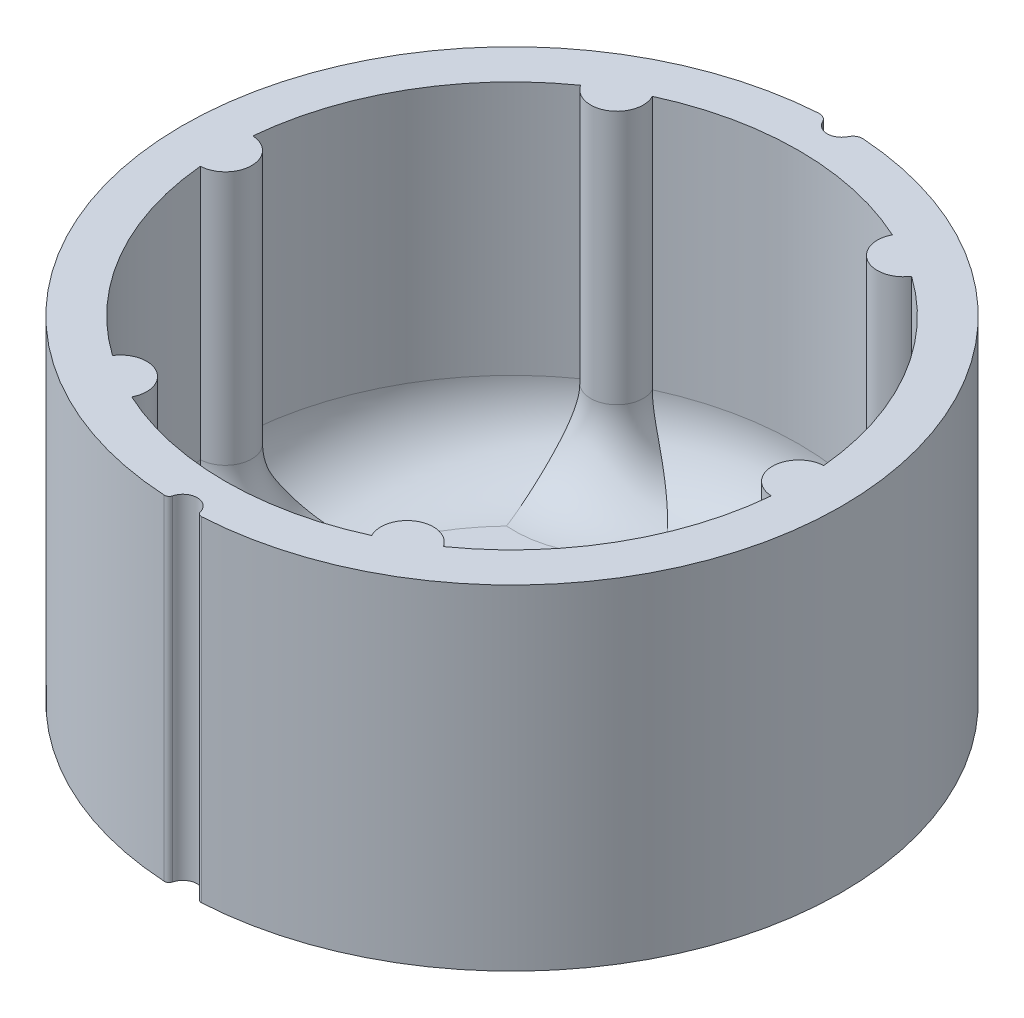
from build123d import *

# Parameters (mm, degrees)
BOSS_EXTRUDE1_DEPTH = 35
CUT_EXTRUDE2_DEPTH  = 61.012997416
BOSS_EXTRUDE2_DEPTH = 0.4
FILLET1_R           = 8


with BuildPart() as part:
    # Sketch1 → Boss-Extrude1 (new body)
    with BuildSketch(Plane(origin=(0, 0, 0), x_dir=(1, 0, 0), z_dir=(0, 1, 0))):
        with BuildLine():
            ThreePointArc((1.451818925, -34.068556857), (1.641248992, -34.346908706), (1.964225605, -34.442038138))
            ThreePointArc((1.964225605, -34.442038138), (26.591847487, -21.978073076), (34.198225299, 4.555174015))
            ThreePointArc((34.198225299, 4.555174015), (23.590291339, 25.176355888), (2.324135821, 34.423627607))
            ThreePointArc((2.324135821, 34.423627607), (1.751838249, 34.289058819), (1.354061739, 33.856153382))
            ThreePointArc((1.354061739, 33.856153382), (0, 33.001534515), (-1.354061739, 33.856153382))
            ThreePointArc((-1.354061739, 33.856153382), (-1.751838249, 34.289058819), (-2.324135821, 34.423627607))
            ThreePointArc((-2.324135821, 34.423627607), (-23.590291339, 25.176355888), (-34.198225299, 4.555174015))
            ThreePointArc((-34.198225299, 4.555174015), (-26.591847487, -21.978073076), (-1.964225605, -34.442038138))
            ThreePointArc((-1.964225605, -34.442038138), (-1.641248992, -34.346908706), (-1.451818925, -34.068556857))
            ThreePointArc((-1.451818925, -34.068556857), (0, -32.945679925), (1.451818925, -34.068556857))
        make_face()
        with BuildLine():
            Line((-2.417, 3.787737139), (0, 3.787737139))
            Line((0, 3.787737139), (2.417, 3.787737139))
            ThreePointArc((2.417, 3.787737139), (0, -4.489512172), (-2.417, 3.787737139))
        make_face(mode=Mode.SUBTRACT)
    extrude(amount=BOSS_EXTRUDE1_DEPTH)

    # Sketch2 → Cut-Extrude2 (cut, through all)
    with BuildSketch(Plane(origin=(0, 0, 0), x_dir=(1, 0, 0), z_dir=(0, 1, 0))):
        with BuildLine():
            ThreePointArc((-17.316046237, 24.498051815), (-25.980762114, 15), (-29.873958333, 2.747110027))
            ThreePointArc((-29.873958333, 2.747110027), (-27.25, 0), (-29.873958333, -2.747110027))
            ThreePointArc((-29.873958333, -2.747110027), (-25.980762114, -15), (-17.316046237, -24.498051815))
            ThreePointArc((-17.316046237, -24.498051815), (-13.625, -23.599192253), (-12.557912097, -27.245161842))
            ThreePointArc((-12.557912097, -27.245161842), (0, -30), (12.557912097, -27.245161842))
            ThreePointArc((12.557912097, -27.245161842), (13.625, -23.599192253), (17.316046237, -24.498051815))
            ThreePointArc((17.316046237, -24.498051815), (25.980762114, -15), (29.873958333, -2.747110027))
            ThreePointArc((29.873958333, -2.747110027), (27.25, 0), (29.873958333, 2.747110027))
            ThreePointArc((29.873958333, 2.747110027), (25.980762114, 15), (17.316046237, 24.498051815))
            ThreePointArc((17.316046237, 24.498051815), (13.625, 23.599192253), (12.557912097, 27.245161842))
            ThreePointArc((12.557912097, 27.245161842), (0, 30), (-12.557912097, 27.245161842))
            ThreePointArc((-12.557912097, 27.245161842), (-13.625, 23.599192253), (-17.316046237, 24.498051815))
        make_face()
    extrude(amount=CUT_EXTRUDE2_DEPTH, mode=Mode.SUBTRACT)

    # Sketch2_2 → Boss-Extrude2 (add)
    with BuildSketch(Plane(origin=(0, 0, 0), x_dir=(1, 0, 0), z_dir=(0, 1, 0))):
        with BuildLine():
            ThreePointArc((-17.316046237, 24.498051815), (-25.980762114, 15), (-29.873958333, 2.747110027))
            ThreePointArc((-29.873958333, 2.747110027), (-27.25, 0), (-29.873958333, -2.747110027))
            ThreePointArc((-29.873958333, -2.747110027), (-25.980762114, -15), (-17.316046237, -24.498051815))
            ThreePointArc((-17.316046237, -24.498051815), (-13.625, -23.599192253), (-12.557912097, -27.245161842))
            ThreePointArc((-12.557912097, -27.245161842), (0, -30), (12.557912097, -27.245161842))
            ThreePointArc((12.557912097, -27.245161842), (13.625, -23.599192253), (17.316046237, -24.498051815))
            ThreePointArc((17.316046237, -24.498051815), (25.980762114, -15), (29.873958333, -2.747110027))
            ThreePointArc((29.873958333, -2.747110027), (27.25, 0), (29.873958333, 2.747110027))
            ThreePointArc((29.873958333, 2.747110027), (25.980762114, 15), (17.316046237, 24.498051815))
            ThreePointArc((17.316046237, 24.498051815), (13.625, 23.599192253), (12.557912097, 27.245161842))
            ThreePointArc((12.557912097, 27.245161842), (0, 30), (-12.557912097, 27.245161842))
            ThreePointArc((-12.557912097, 27.245161842), (-13.625, 23.599192253), (-17.316046237, 24.498051815))
        make_face()
    extrude(amount=BOSS_EXTRUDE2_DEPTH)

    # Fillet1
    fillet1_edges = [part.edges().sort_by_distance(p)[0] for p in [
        (13.625, 0.4, 23.599192253),
        (0, 0.4, 30),
        (-13.625, 0.4, 23.599192253),
        (-25.980762114, 0.4, 15),
        (-27.25, 0.4, 0),
        (-25.980762114, 0.4, -15),
        (-13.625, 0.4, -23.599192253),
        (0, 0.4, -30),
        (13.625, 0.4, -23.599192253),
        (25.980762114, 0.4, -15),
        (27.25, 0.4, 0),
        (25.980762114, 0.4, 15),
    ]]
    fillet(fillet1_edges, radius=FILLET1_R)


solid = part.part
